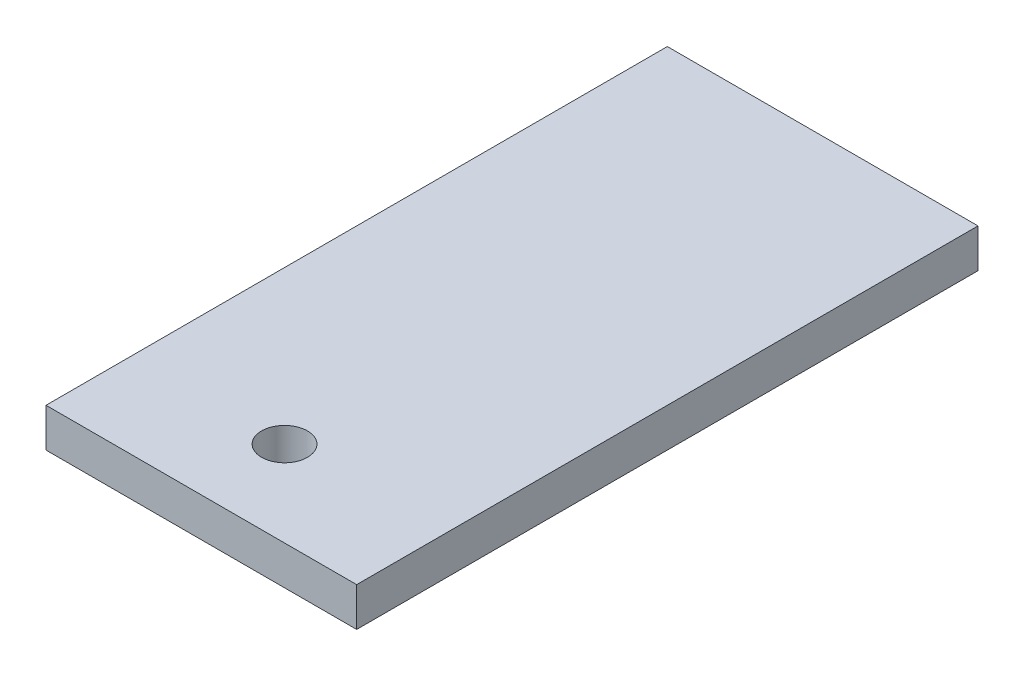
from build123d import *

# Parameters (mm, degrees)
SKETCH1_W           = 203.2
SKETCH1_H           = 406.4
BOSS_EXTRUDE1_DEPTH = 25.4
SKETCH3_R           = 15
CUT_EXTRUDE2_DEPTH  = 25.4


with BuildPart() as part:
    # Sketch1 → Boss-Extrude1 (new body)
    with BuildSketch(Plane(origin=(0, 0, 0), x_dir=(1, 0, 0), z_dir=(0, 1, 0))):
        with Locations((101.6, 203.2)):
            Rectangle(SKETCH1_W, SKETCH1_H)
    extrude(amount=BOSS_EXTRUDE1_DEPTH)

    # Sketch3 → Cut-Extrude2 (cut)
    with BuildSketch(Plane(origin=(0, 25.4, 0), x_dir=(1, 0, 0), z_dir=(0, 1, 0))):
        with Locations((100, 56)):
            Circle(SKETCH3_R)
    extrude(amount=-CUT_EXTRUDE2_DEPTH, mode=Mode.SUBTRACT)


solid = part.part
